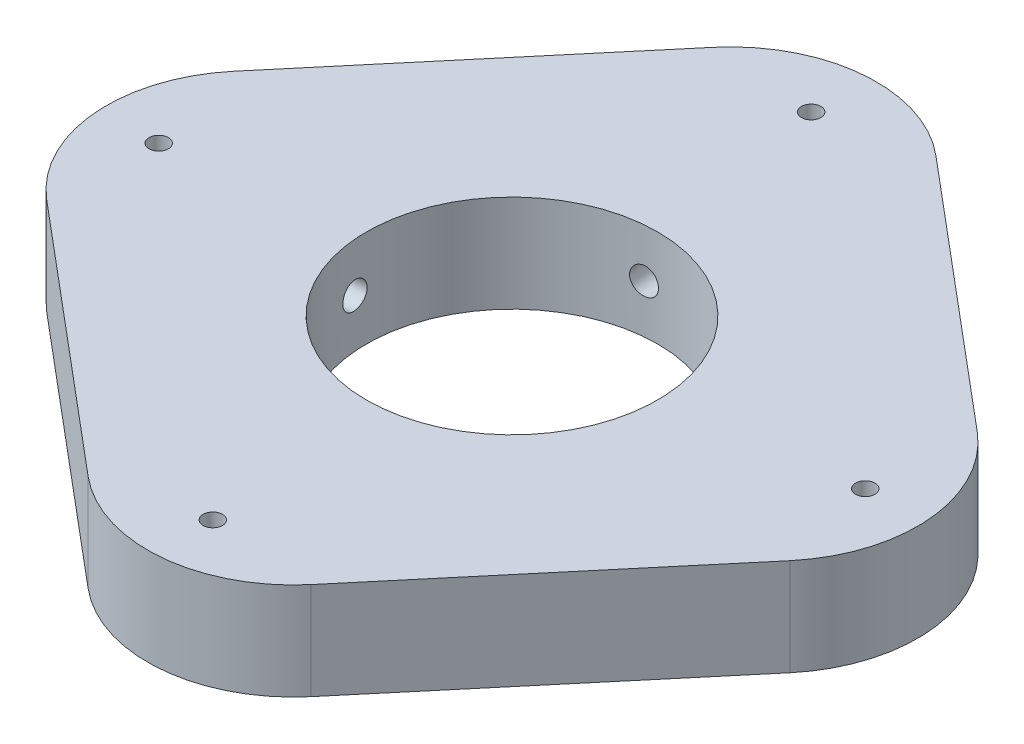
from build123d import *

# Parameters (mm, degrees)
SKETCH2_R               = 16.2
BOSS_EXTRUDE2_DEPTH     = 10
SKETCH3_R               = 16.2
SKETCH3_R_2             = 1
CUT_EXTRUDE2_DEPTH      = 10
SKETCH4_R               = 16.2
SKETCH4_R_2             = 15
BOSS_EXTRUDE3_DEPTH     = 10
SKETCH7_R               = 1.375
CUT_EXTRUDE3_DEPTH      = 25
CUT_EXTRUDE3_DEPTH_BACK = 25
SKETCH8_R               = 1.375
CUT_EXTRUDE4_DEPTH      = 25
CUT_EXTRUDE4_DEPTH_BACK = 25


with BuildPart() as part:
    # Sketch2 → Boss-Extrude2 (new body)
    with BuildSketch(Plane(origin=(0, 0, 0), x_dir=(1, 0, 0), z_dir=(0, 1, 0))):
        with BuildLine():
            Line((33.90162956, 14.020502411), (7.113925389, 36.546463106))
            ThreePointArc((7.113925389, 36.546463106), (-3.831561071, 40.010315675), (-14.020502411, 34.720001617))
            Line((-14.020502411, 34.720001617), (-36.546463106, 7.932297446))
            ThreePointArc((-36.546463106, 7.932297446), (-40.010315675, -3.013189014), (-34.720001617, -13.202130354))
            Line((-34.720001617, -13.202130354), (-7.932297446, -35.728091049))
            ThreePointArc((-7.932297446, -35.728091049), (3.013189014, -39.191943618), (13.202130354, -33.90162956))
            Line((13.202130354, -33.90162956), (35.728091049, -7.113925389))
            ThreePointArc((35.728091049, -7.113925389), (39.191943618, 3.831561071), (33.90162956, 14.020502411))
        make_face()
        with Locations((-0.409186029, 0.409186029)):
            Circle(SKETCH2_R, mode=Mode.SUBTRACT)
    extrude(amount=BOSS_EXTRUDE2_DEPTH)

    # Sketch3 → Cut-Extrude2 (cut)
    with BuildSketch(Plane(origin=(0, 10, 0), x_dir=(1, 0, 0), z_dir=(0, 1, 0))):
        with Locations((-0.409186029, 0.409186029)):
            Circle(SKETCH3_R)
        with Locations((-34.010315675, -2.376211247)):
            Circle(SKETCH3_R_2)
        with Locations((-3.194583304, 34.010315675)):
            Circle(SKETCH3_R_2)
        with Locations((33.191943618, 3.194583304)):
            Circle(SKETCH3_R_2)
        with Locations((2.376211247, -33.191943618)):
            Circle(SKETCH3_R_2)
    extrude(amount=-CUT_EXTRUDE2_DEPTH, mode=Mode.SUBTRACT)

    # Sketch4 → Boss-Extrude3 (add)
    with BuildSketch(Plane(origin=(0, 10, 0), x_dir=(1, 0, 0), z_dir=(0, 1, 0))):
        with Locations((-0.409186029, 0.409186029)):
            Circle(SKETCH4_R)
        with Locations((-0.409186029, 0.409186029)):
            Circle(SKETCH4_R_2, mode=Mode.SUBTRACT)
    extrude(amount=-BOSS_EXTRUDE3_DEPTH)

    # Sketch7 → Cut-Extrude3 (cut, two sides)
    with BuildSketch(Plane(origin=(-0.371052455, 0, 0.032066779), x_dir=(-0.08610022, 0, -0.996286481), z_dir=(0.996286481, 0, -0.08610022))) as cut_extrude3_sk:
        with Locations((0.442897516, 5)):
            Circle(SKETCH7_R)
    extrude(amount=CUT_EXTRUDE3_DEPTH, mode=Mode.SUBTRACT)
    extrude(cut_extrude3_sk.sketch, amount=-CUT_EXTRUDE3_DEPTH_BACK, mode=Mode.SUBTRACT)

    # Sketch8 → Cut-Extrude4 (cut, two sides)
    with BuildSketch(Plane(origin=(-0.038133574, 0, -0.441252807), x_dir=(0.996286481, 0, -0.08610022), z_dir=(0.08610022, 0, 0.996286481))) as cut_extrude4_sk:
        with Locations((-0.372435501, 5)):
            Circle(SKETCH8_R)
    extrude(amount=CUT_EXTRUDE4_DEPTH, mode=Mode.SUBTRACT)
    extrude(cut_extrude4_sk.sketch, amount=-CUT_EXTRUDE4_DEPTH_BACK, mode=Mode.SUBTRACT)


solid = part.part
